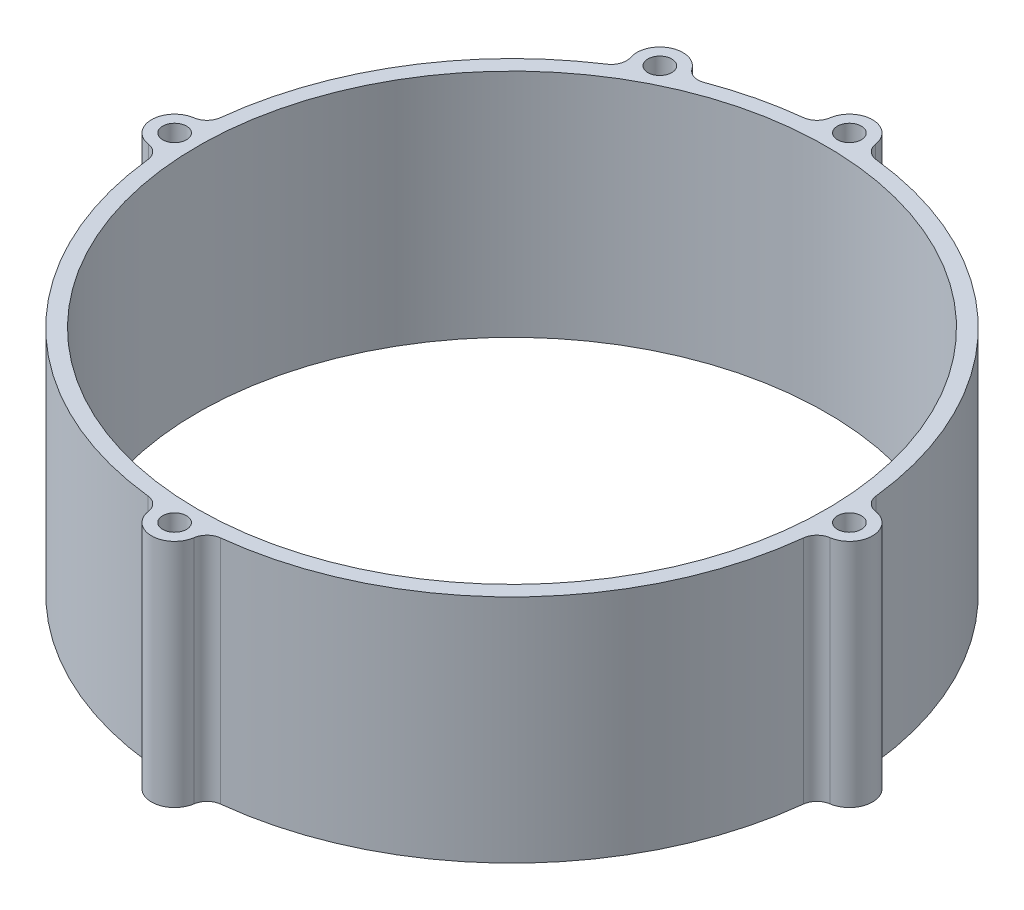
from build123d import *

# Parameters (mm, degrees)
SKETCH_1_R      = 40.9
SKETCH_1_R_2    = 1.55
EXTRUDE_1_DEPTH = 30


with BuildPart() as part:
    # 草图1 → 凸台-拉伸1 (new body)
    with BuildSketch(Plane(origin=(0, 0, 0), x_dir=(1, 0, 0), z_dir=(0, 1, 0))):
        with BuildLine():
            ThreePointArc((2.968149583, 44.335990888), (0, 46.9), (-2.968149583, 44.335990888))
            ThreePointArc((-2.968149583, 44.335990888), (-3.557987573, 43.187596963), (-4.726563367, 42.638827361))
            ThreePointArc((-4.726563367, 42.638827361), (-9.998714121, 41.718529647), (-15.115253688, 40.148961455))
            ThreePointArc((-15.115253688, 40.148961455), (-16.405630214, 40.108391944), (-17.451956512, 40.864645036))
            ThreePointArc((-17.451956512, 40.864645036), (-21.259908884, 41.80462025), (-22.74331541, 38.173703045))
            ThreePointArc((-22.74331541, 38.173703045), (-22.748500974, 36.882699338), (-23.541359728, 35.863831114))
            ThreePointArc((-23.541359728, 35.863831114), (-36.569613773, 22.429296657), (-42.638827361, 4.726563367))
            ThreePointArc((-42.638827361, 4.726563367), (-43.187596963, 3.557987573), (-44.335990888, 2.968149583))
            ThreePointArc((-44.335990888, 2.968149583), (-46.9, 0), (-44.335990888, -2.968149583))
            ThreePointArc((-44.335990888, -2.968149583), (-43.187596963, -3.557987573), (-42.638827361, -4.726563367))
            ThreePointArc((-42.638827361, -4.726563367), (-30.334880913, -30.334880913), (-4.726563367, -42.638827361))
            ThreePointArc((-4.726563367, -42.638827361), (-3.557987573, -43.187596963), (-2.968149583, -44.335990888))
            ThreePointArc((-2.968149583, -44.335990888), (0, -46.9), (2.968149583, -44.335990888))
            ThreePointArc((2.968149583, -44.335990888), (3.557987573, -43.187596963), (4.726563367, -42.638827361))
            ThreePointArc((4.726563367, -42.638827361), (30.334880913, -30.334880913), (42.638827361, -4.726563367))
            ThreePointArc((42.638827361, -4.726563367), (43.187596963, -3.557987573), (44.335990888, -2.968149583))
            ThreePointArc((44.335990888, -2.968149583), (46.9, 0), (44.335990888, 2.968149583))
            ThreePointArc((44.335990888, 2.968149583), (43.187596963, 3.557987573), (42.638827361, 4.726563367))
            ThreePointArc((42.638827361, 4.726563367), (30.334880913, 30.334880913), (4.726563367, 42.638827361))
            ThreePointArc((4.726563367, 42.638827361), (3.557987573, 43.187596963), (2.968149583, 44.335990888))
        make_face()
        Circle(SKETCH_1_R, mode=Mode.SUBTRACT)
        with Locations((0, 43.9)):
            Circle(SKETCH_1_R_2, mode=Mode.SUBTRACT)
        with Locations((43.9, 0)):
            Circle(SKETCH_1_R_2, mode=Mode.SUBTRACT)
        with Locations((0, -43.9)):
            Circle(SKETCH_1_R_2, mode=Mode.SUBTRACT)
        with Locations((-43.9, 0)):
            Circle(SKETCH_1_R_2, mode=Mode.SUBTRACT)
        with Locations((-19.9, 39.130550724)):
            Circle(SKETCH_1_R_2, mode=Mode.SUBTRACT)
    extrude(amount=EXTRUDE_1_DEPTH)


solid = part.part
